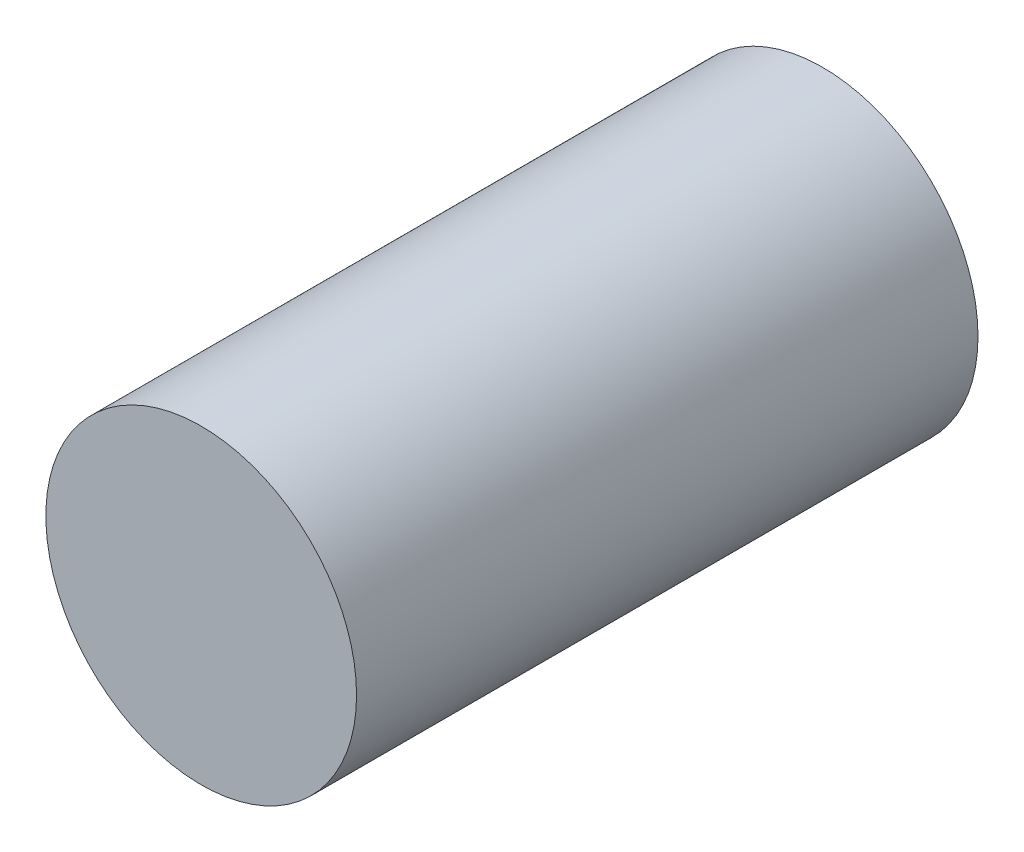
from build123d import *

# Parameters (mm, degrees)
SKETCH1_R           = 25.4
BOSS_EXTRUDE1_DEPTH = 101.6


with BuildPart() as part:
    # Sketch1 → Boss-Extrude1 (new body)
    with BuildSketch(Plane.XY):
        Circle(SKETCH1_R)
    extrude(amount=BOSS_EXTRUDE1_DEPTH)


solid = part.part
